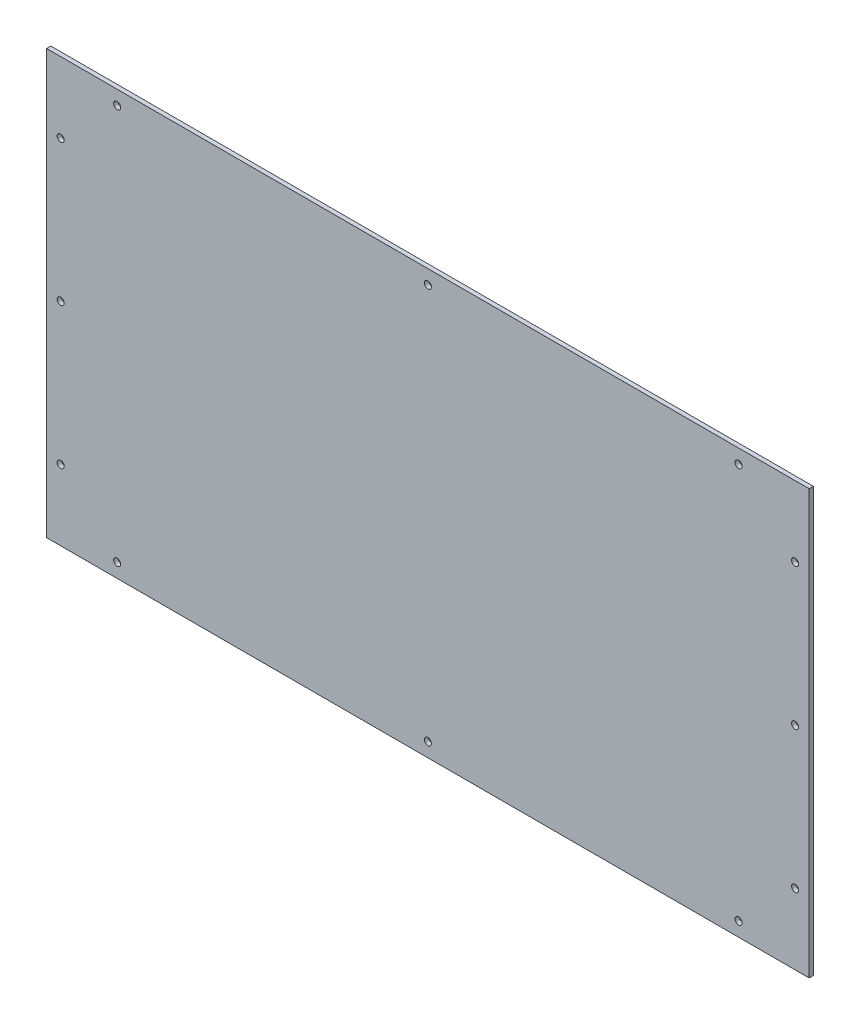
from build123d import *

# Parameters (mm, degrees)
CROQUIS1_W              = 540
CROQUIS1_H              = 300
SALIENTE_EXTRUIR1_DEPTH = 3
CROQUIS2_R              = 2.5
CORTAR_EXTRUIR1_DEPTH   = 4


with BuildPart() as part:
    # Croquis1 → Saliente-Extruir1 (new body)
    with BuildSketch(Plane.XY):
        Rectangle(CROQUIS1_W, CROQUIS1_H)
    extrude(amount=SALIENTE_EXTRUIR1_DEPTH)

    # Croquis2 → Cortar-Extruir1 (cut, through all)
    with BuildSketch(Plane.XY.offset(3)):
        with Locations((0, 140)):
            Circle(CROQUIS2_R)
        with Locations((-220, 140)):
            Circle(CROQUIS2_R)
        with Locations((-260, 0)):
            Circle(CROQUIS2_R)
        with Locations((-260, 100)):
            Circle(CROQUIS2_R)
        with Locations((-260, -100)):
            Circle(CROQUIS2_R)
        with Locations((220, 140)):
            Circle(CROQUIS2_R)
        with Locations((260, -100)):
            Circle(CROQUIS2_R)
        with Locations((260, 0)):
            Circle(CROQUIS2_R)
        with Locations((260, 100)):
            Circle(CROQUIS2_R)
        with Locations((220, -140)):
            Circle(CROQUIS2_R)
        with Locations((0, -140)):
            Circle(CROQUIS2_R)
        with Locations((-220, -140)):
            Circle(CROQUIS2_R)
    extrude(amount=-CORTAR_EXTRUIR1_DEPTH, mode=Mode.SUBTRACT)


solid = part.part
